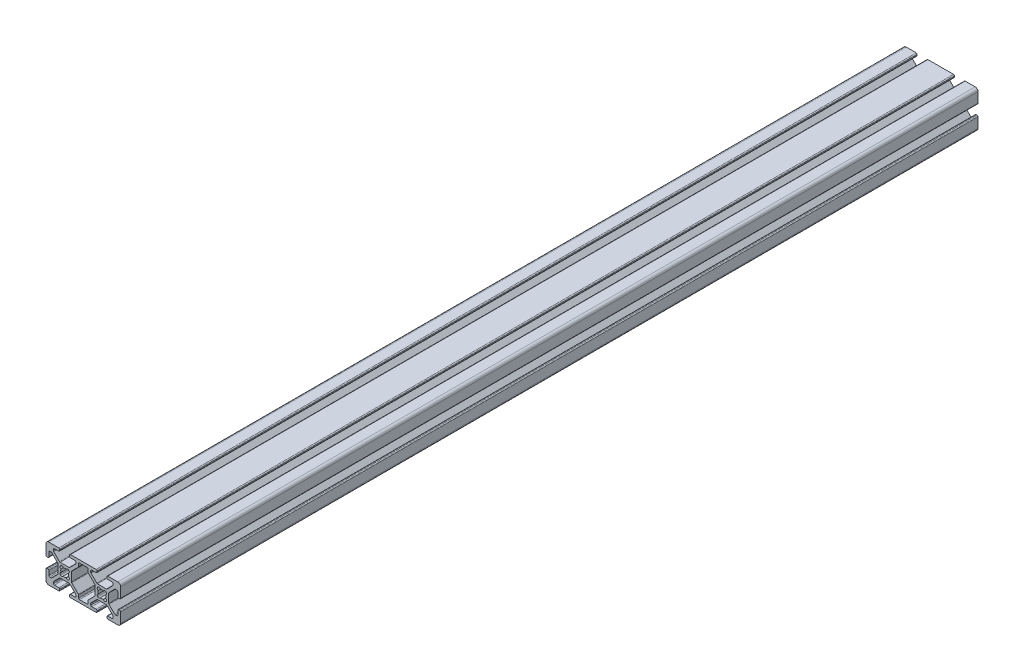
from build123d import *

# Parameters (mm, degrees)
EXTRUDE1_DEPTH = 460


with BuildPart() as part:
    # Sketch1 → Extrude1 (new body)
    with BuildSketch(Plane.XY):
        with BuildLine():
            Line((-22.383919339, -3.655), (-17.616080661, -3.655))
            ThreePointArc((-17.616080661, -3.655), (-17.421677478, -3.693669197), (-17.256870417, -3.803789755))
            Line((-17.256870417, -3.803789755), (-14.153789755, -6.906870417))
            ThreePointArc((-14.153789755, -6.906870417), (-14.043669197, -7.071677478), (-14.005, -7.266080661))
            Line((-14.005, -7.266080661), (-14.005, -7.992))
            ThreePointArc((-14.005, -7.992), (-14.153789755, -8.351210245), (-14.513, -8.5))
            Line((-14.513, -8.5), (-16.862, -8.5))
            ThreePointArc((-16.862, -8.5), (-17.221210245, -8.648789755), (-17.37, -9.008))
            Line((-17.37, -9.008), (-17.37, -9.492))
            ThreePointArc((-17.37, -9.492), (-17.221210245, -9.851210245), (-16.862, -10))
            Line((-16.862, -10), (-3.138, -10))
            ThreePointArc((-3.138, -10), (-2.778789755, -9.851210245), (-2.63, -9.492))
            Line((-2.63, -9.492), (-2.63, -9.008))
            ThreePointArc((-2.63, -9.008), (-2.778789755, -8.648789755), (-3.138, -8.5))
            Line((-3.138, -8.5), (-5.487, -8.5))
            ThreePointArc((-5.487, -8.5), (-5.846210245, -8.351210245), (-5.995, -7.992))
            Line((-5.995, -7.992), (-5.995, -7.266080661))
            ThreePointArc((-5.995, -7.266080661), (-5.956330803, -7.071677478), (-5.846210245, -6.906870417))
            Line((-5.846210245, -6.906870417), (-2.743129583, -3.803789755))
            ThreePointArc((-2.743129583, -3.803789755), (-2.578322522, -3.693669197), (-2.383919339, -3.655))
            Line((-2.383919339, -3.655), (2.383919339, -3.655))
            ThreePointArc((2.383919339, -3.655), (2.578322522, -3.693669197), (2.743129583, -3.803789755))
            Line((2.743129583, -3.803789755), (5.846210245, -6.906870417))
            ThreePointArc((5.846210245, -6.906870417), (5.956330803, -7.071677478), (5.995, -7.266080661))
            Line((5.995, -7.266080661), (5.995, -7.992))
            ThreePointArc((5.995, -7.992), (5.846210245, -8.351210245), (5.487, -8.5))
            Line((5.487, -8.5), (3.138, -8.5))
            ThreePointArc((3.138, -8.5), (2.778789755, -8.648789755), (2.63, -9.008))
            Line((2.63, -9.008), (2.63, -9.492))
            ThreePointArc((2.63, -9.492), (2.778789755, -9.851210245), (3.138, -10))
            Line((3.138, -10), (8.5, -10))
            ThreePointArc((8.5, -10), (9.560660172, -9.560660172), (10, -8.5))
            Line((10, -8.5), (10, -3.138))
            ThreePointArc((10, -3.138), (9.851210245, -2.778789755), (9.492, -2.63))
            Line((9.492, -2.63), (9.008, -2.63))
            ThreePointArc((9.008, -2.63), (8.648789755, -2.778789755), (8.5, -3.138))
            Line((8.5, -3.138), (8.5, -5.487))
            ThreePointArc((8.5, -5.487), (8.351210245, -5.846210245), (7.992, -5.995))
            Line((7.992, -5.995), (7.266080661, -5.995))
            ThreePointArc((7.266080661, -5.995), (7.071677478, -5.956330803), (6.906870417, -5.846210245))
            Line((6.906870417, -5.846210245), (3.803789755, -2.743129583))
            ThreePointArc((3.803789755, -2.743129583), (3.693669197, -2.578322522), (3.655, -2.383919339))
            Line((3.655, -2.383919339), (3.655, 2.383919339))
            ThreePointArc((3.655, 2.383919339), (3.693669197, 2.578322522), (3.803789755, 2.743129583))
            Line((3.803789755, 2.743129583), (6.906870417, 5.846210245))
            ThreePointArc((6.906870417, 5.846210245), (7.071677478, 5.956330803), (7.266080661, 5.995))
            Line((7.266080661, 5.995), (7.992, 5.995))
            ThreePointArc((7.992, 5.995), (8.351210245, 5.846210245), (8.5, 5.487))
            Line((8.5, 5.487), (8.5, 3.138))
            ThreePointArc((8.5, 3.138), (8.648789755, 2.778789755), (9.008, 2.63))
            Line((9.008, 2.63), (9.492, 2.63))
            ThreePointArc((9.492, 2.63), (9.851210245, 2.778789755), (10, 3.138))
            Line((10, 3.138), (10, 8.5))
            ThreePointArc((10, 8.5), (9.560660172, 9.560660172), (8.5, 10))
            Line((8.5, 10), (3.138, 10))
            ThreePointArc((3.138, 10), (2.778789755, 9.851210245), (2.63, 9.492))
            Line((2.63, 9.492), (2.63, 9.008))
            ThreePointArc((2.63, 9.008), (2.778789755, 8.648789755), (3.138, 8.5))
            Line((3.138, 8.5), (5.487, 8.5))
            ThreePointArc((5.487, 8.5), (5.846210245, 8.351210245), (5.995, 7.992))
            Line((5.995, 7.992), (5.995, 7.266080661))
            ThreePointArc((5.995, 7.266080661), (5.956330803, 7.071677478), (5.846210245, 6.906870417))
            Line((5.846210245, 6.906870417), (2.743129583, 3.803789755))
            ThreePointArc((2.743129583, 3.803789755), (2.578322522, 3.693669197), (2.383919339, 3.655))
            Line((2.383919339, 3.655), (-2.383919339, 3.655))
            ThreePointArc((-2.383919339, 3.655), (-2.578322522, 3.693669197), (-2.743129583, 3.803789755))
            Line((-2.743129583, 3.803789755), (-5.846210245, 6.906870417))
            ThreePointArc((-5.846210245, 6.906870417), (-5.956330803, 7.071677478), (-5.995, 7.266080661))
            Line((-5.995, 7.266080661), (-5.995, 7.992))
            ThreePointArc((-5.995, 7.992), (-5.846210245, 8.351210245), (-5.487, 8.5))
            Line((-5.487, 8.5), (-3.138, 8.5))
            ThreePointArc((-3.138, 8.5), (-2.778789755, 8.648789755), (-2.63, 9.008))
            Line((-2.63, 9.008), (-2.63, 9.492))
            ThreePointArc((-2.63, 9.492), (-2.778789755, 9.851210245), (-3.138, 10))
            Line((-3.138, 10), (-16.862, 10))
            ThreePointArc((-16.862, 10), (-17.221210245, 9.851210245), (-17.37, 9.492))
            Line((-17.37, 9.492), (-17.37, 9.008))
            ThreePointArc((-17.37, 9.008), (-17.221210245, 8.648789755), (-16.862, 8.5))
            Line((-16.862, 8.5), (-14.513, 8.5))
            ThreePointArc((-14.513, 8.5), (-14.153789755, 8.351210245), (-14.005, 7.992))
            Line((-14.005, 7.992), (-14.005, 7.266080661))
            ThreePointArc((-14.005, 7.266080661), (-14.043669197, 7.071677478), (-14.153789755, 6.906870417))
            Line((-14.153789755, 6.906870417), (-17.256870417, 3.803789755))
            ThreePointArc((-17.256870417, 3.803789755), (-17.421677478, 3.693669197), (-17.616080661, 3.655))
            Line((-17.616080661, 3.655), (-22.383919339, 3.655))
            ThreePointArc((-22.383919339, 3.655), (-22.578322522, 3.693669197), (-22.743129583, 3.803789755))
            Line((-22.743129583, 3.803789755), (-25.846210245, 6.906870417))
            ThreePointArc((-25.846210245, 6.906870417), (-25.956330803, 7.071677478), (-25.995, 7.266080661))
            Line((-25.995, 7.266080661), (-25.995, 7.992))
            ThreePointArc((-25.995, 7.992), (-25.846210245, 8.351210245), (-25.487, 8.5))
            Line((-25.487, 8.5), (-23.138, 8.5))
            ThreePointArc((-23.138, 8.5), (-22.778789755, 8.648789755), (-22.63, 9.008))
            Line((-22.63, 9.008), (-22.63, 9.492))
            ThreePointArc((-22.63, 9.492), (-22.778789755, 9.851210245), (-23.138, 10))
            Line((-23.138, 10), (-28.5, 10))
            ThreePointArc((-28.5, 10), (-29.560660172, 9.560660172), (-30, 8.5))
            Line((-30, 8.5), (-30, 3.138))
            ThreePointArc((-30, 3.138), (-29.851210245, 2.778789755), (-29.492, 2.63))
            Line((-29.492, 2.63), (-29.008, 2.63))
            ThreePointArc((-29.008, 2.63), (-28.648789755, 2.778789755), (-28.5, 3.138))
            Line((-28.5, 3.138), (-28.5, 5.487))
            ThreePointArc((-28.5, 5.487), (-28.351210245, 5.846210245), (-27.992, 5.995))
            Line((-27.992, 5.995), (-27.266080661, 5.995))
            ThreePointArc((-27.266080661, 5.995), (-27.071677478, 5.956330803), (-26.906870417, 5.846210245))
            Line((-26.906870417, 5.846210245), (-23.803789755, 2.743129583))
            ThreePointArc((-23.803789755, 2.743129583), (-23.693669197, 2.578322522), (-23.655, 2.383919339))
            Line((-23.655, 2.383919339), (-23.655, -2.383919339))
            ThreePointArc((-23.655, -2.383919339), (-23.693669197, -2.578322522), (-23.803789755, -2.743129583))
            Line((-23.803789755, -2.743129583), (-26.906870417, -5.846210245))
            ThreePointArc((-26.906870417, -5.846210245), (-27.071677478, -5.956330803), (-27.266080661, -5.995))
            Line((-27.266080661, -5.995), (-27.992, -5.995))
            ThreePointArc((-27.992, -5.995), (-28.351210245, -5.846210245), (-28.5, -5.487))
            Line((-28.5, -5.487), (-28.5, -3.138))
            ThreePointArc((-28.5, -3.138), (-28.648789755, -2.778789755), (-29.008, -2.63))
            Line((-29.008, -2.63), (-29.492, -2.63))
            ThreePointArc((-29.492, -2.63), (-29.851210245, -2.778789755), (-30, -3.138))
            Line((-30, -3.138), (-30, -8.5))
            ThreePointArc((-30, -8.5), (-29.560660172, -9.560660172), (-28.5, -10))
            Line((-28.5, -10), (-23.138, -10))
            ThreePointArc((-23.138, -10), (-22.778789755, -9.851210245), (-22.63, -9.492))
            Line((-22.63, -9.492), (-22.63, -9.008))
            ThreePointArc((-22.63, -9.008), (-22.778789755, -8.648789755), (-23.138, -8.5))
            Line((-23.138, -8.5), (-25.487, -8.5))
            ThreePointArc((-25.487, -8.5), (-25.846210245, -8.351210245), (-25.995, -7.992))
            Line((-25.995, -7.992), (-25.995, -7.266080661))
            ThreePointArc((-25.995, -7.266080661), (-25.956330803, -7.071677478), (-25.846210245, -6.906870417))
            Line((-25.846210245, -6.906870417), (-22.743129583, -3.803789755))
            ThreePointArc((-22.743129583, -3.803789755), (-22.578322522, -3.693669197), (-22.383919339, -3.655))
        make_face()
        with BuildLine():
            Line((-2.124900844, -2.304505966), (-2.304505966, -2.124900844))
            ThreePointArc((-2.304505966, -2.124900844), (-2.505938017, -1.356467811), (-1.935133506, -0.803976718))
            ThreePointArc((-1.935133506, -0.803976718), (-2.0955, 0), (-1.935133506, 0.803976718))
            ThreePointArc((-1.935133506, 0.803976718), (-2.505938017, 1.356467811), (-2.304505966, 2.124900844))
            Line((-2.304505966, 2.124900844), (-2.124900844, 2.304505966))
            ThreePointArc((-2.124900844, 2.304505966), (-1.356467811, 2.505938017), (-0.803976718, 1.935133506))
            ThreePointArc((-0.803976718, 1.935133506), (0, 2.0955), (0.803976718, 1.935133506))
            ThreePointArc((0.803976718, 1.935133506), (1.356467811, 2.505938017), (2.124900844, 2.304505966))
            Line((2.124900844, 2.304505966), (2.304505966, 2.124900844))
            ThreePointArc((2.304505966, 2.124900844), (2.505938017, 1.356467811), (1.935133506, 0.803976718))
            ThreePointArc((1.935133506, 0.803976718), (2.0955, 0), (1.935133506, -0.803976718))
            ThreePointArc((1.935133506, -0.803976718), (2.505938017, -1.356467811), (2.304505966, -2.124900844))
            Line((2.304505966, -2.124900844), (2.124900844, -2.304505966))
            ThreePointArc((2.124900844, -2.304505966), (1.356467811, -2.505938017), (0.803976718, -1.935133506))
            ThreePointArc((0.803976718, -1.935133506), (0, -2.0955), (-0.803976718, -1.935133506))
            ThreePointArc((-0.803976718, -1.935133506), (-1.356467811, -2.505938017), (-2.124900844, -2.304505966))
        make_face(mode=Mode.SUBTRACT)
        with BuildLine():
            Line((-12.505, -7.992), (-12.505, -6.644760318))
            ThreePointArc((-12.505, -6.644760318), (-12.543669197, -6.450357134), (-12.653789755, -6.285550073))
            Line((-12.653789755, -6.285550073), (-16.196210245, -2.743129583))
            ThreePointArc((-16.196210245, -2.743129583), (-16.306330803, -2.578322522), (-16.345, -2.383919339))
            Line((-16.345, -2.383919339), (-16.345, 2.383919339))
            ThreePointArc((-16.345, 2.383919339), (-16.306330803, 2.578322522), (-16.196210245, 2.743129583))
            Line((-16.196210245, 2.743129583), (-12.653789755, 6.285550073))
            ThreePointArc((-12.653789755, 6.285550073), (-12.543669197, 6.450357134), (-12.505, 6.644760318))
            Line((-12.505, 6.644760318), (-12.505, 7.992))
            ThreePointArc((-12.505, 7.992), (-12.356210245, 8.351210245), (-11.997, 8.5))
            Line((-11.997, 8.5), (-8.003, 8.5))
            ThreePointArc((-8.003, 8.5), (-7.643789755, 8.351210245), (-7.495, 7.992))
            Line((-7.495, 7.992), (-7.495, 6.644760318))
            ThreePointArc((-7.495, 6.644760318), (-7.456330803, 6.450357134), (-7.346210245, 6.285550073))
            Line((-7.346210245, 6.285550073), (-3.803789755, 2.743129583))
            ThreePointArc((-3.803789755, 2.743129583), (-3.693669197, 2.578322522), (-3.655, 2.383919339))
            Line((-3.655, 2.383919339), (-3.655, -2.383919339))
            ThreePointArc((-3.655, -2.383919339), (-3.693669197, -2.578322522), (-3.803789755, -2.743129583))
            Line((-3.803789755, -2.743129583), (-7.346210245, -6.285550073))
            ThreePointArc((-7.346210245, -6.285550073), (-7.456330803, -6.450357134), (-7.495, -6.644760318))
            Line((-7.495, -6.644760318), (-7.495, -7.992))
            ThreePointArc((-7.495, -7.992), (-7.643789755, -8.351210245), (-8.003, -8.5))
            Line((-8.003, -8.5), (-11.997, -8.5))
            ThreePointArc((-11.997, -8.5), (-12.356210245, -8.351210245), (-12.505, -7.992))
        make_face(mode=Mode.SUBTRACT)
        with BuildLine():
            Line((-22.124900844, -2.304505966), (-22.304505966, -2.124900844))
            ThreePointArc((-22.304505966, -2.124900844), (-22.505938017, -1.356467811), (-21.935133506, -0.803976718))
            ThreePointArc((-21.935133506, -0.803976718), (-22.0955, 0), (-21.935133506, 0.803976718))
            ThreePointArc((-21.935133506, 0.803976718), (-22.505938017, 1.356467811), (-22.304505966, 2.124900844))
            Line((-22.304505966, 2.124900844), (-22.124900844, 2.304505966))
            ThreePointArc((-22.124900844, 2.304505966), (-21.356467811, 2.505938017), (-20.803976718, 1.935133506))
            ThreePointArc((-20.803976718, 1.935133506), (-20, 2.0955), (-19.196023282, 1.935133506))
            ThreePointArc((-19.196023282, 1.935133506), (-18.643532189, 2.505938017), (-17.875099156, 2.304505966))
            Line((-17.875099156, 2.304505966), (-17.695494034, 2.124900844))
            ThreePointArc((-17.695494034, 2.124900844), (-17.494061983, 1.356467811), (-18.064866494, 0.803976718))
            ThreePointArc((-18.064866494, 0.803976718), (-17.9045, 0), (-18.064866494, -0.803976718))
            ThreePointArc((-18.064866494, -0.803976718), (-17.494061983, -1.356467811), (-17.695494034, -2.124900844))
            Line((-17.695494034, -2.124900844), (-17.875099156, -2.304505966))
            ThreePointArc((-17.875099156, -2.304505966), (-18.643532189, -2.505938017), (-19.196023282, -1.935133506))
            ThreePointArc((-19.196023282, -1.935133506), (-20, -2.0955), (-20.803976718, -1.935133506))
            ThreePointArc((-20.803976718, -1.935133506), (-21.356467811, -2.505938017), (-22.124900844, -2.304505966))
        make_face(mode=Mode.SUBTRACT)
    extrude(amount=-EXTRUDE1_DEPTH)


solid = part.part
